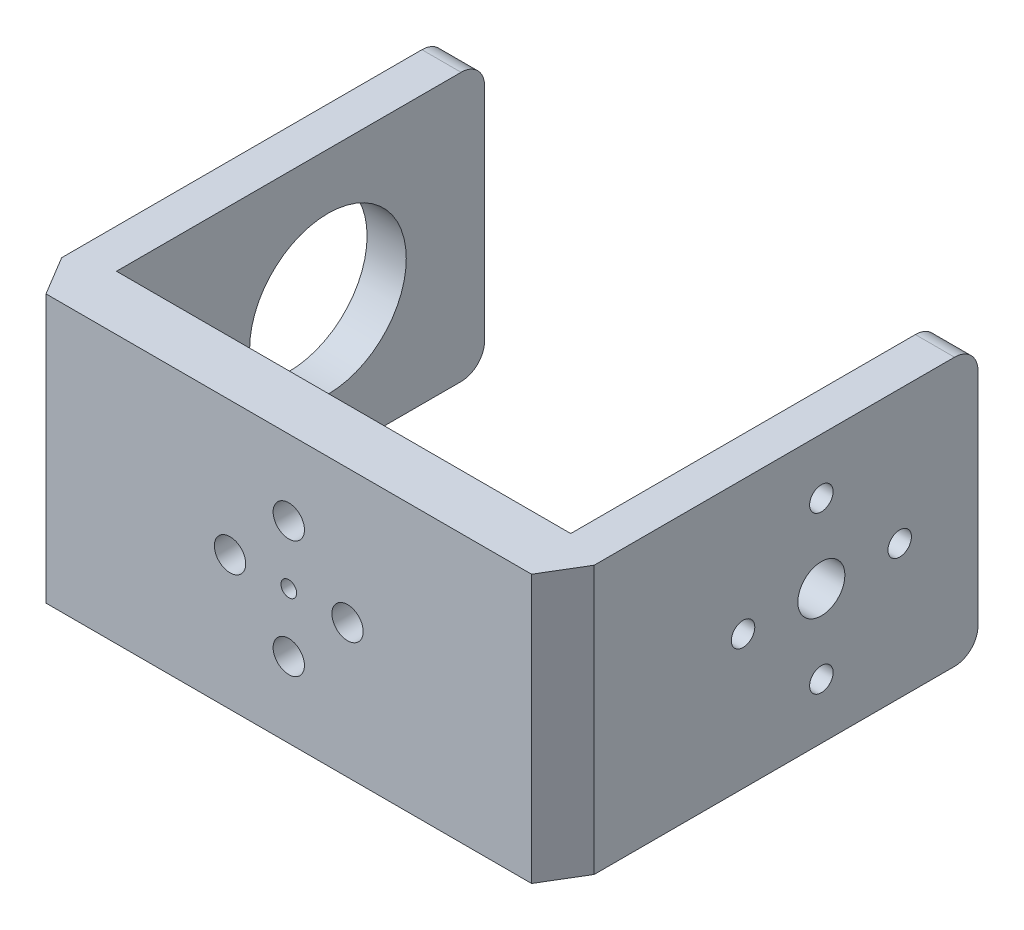
from build123d import *

# Parameters (mm, degrees)
BOSS_EXTRUDE1_DEPTH = 34.2
SKETCH4_R           = 2
SKETCH4_R_2         = 1
CUT_EXTRUDE3_DEPTH  = 7
FILLET1_R           = 3
SKETCH5_R           = 10
CUT_EXTRUDE4_DEPTH  = 5
SKETCH6_R           = 3
SKETCH6_R_2         = 1.5
CUT_EXTRUDE5_DEPTH  = 5


with BuildPart() as part:
    # Sketch1 → Boss-Extrude1 (new body)
    with BuildSketch(Plane(origin=(0, 0, 0), x_dir=(1, 0, 0), z_dir=(0, 1, 0))):
        Polygon((0, 0), (58, 0), (58, 47), (63, 47), (63, -2), (60, -7), (58, -7), (0, -7), (-2, -7), (-5, -2), (-5, 47), (0, 47), align=None)
    extrude(amount=BOSS_EXTRUDE1_DEPTH)

    # Sketch4 → Cut-Extrude3 (cut)
    with BuildSketch(Plane(origin=(0, 0, 0), x_dir=(-1, 0, 0), z_dir=(0, 0, -1))):
        with Locations((-29, 24.6)):
            Circle(SKETCH4_R)
        with Locations((-36.5, 17.1)):
            Circle(SKETCH4_R)
        with Locations((-21.5, 17.1)):
            Circle(SKETCH4_R)
        with Locations((-29, 9.6)):
            Circle(SKETCH4_R)
        with Locations((-29, 17.1)):
            Circle(SKETCH4_R_2)
    extrude(amount=-CUT_EXTRUDE3_DEPTH, mode=Mode.SUBTRACT)

    # Fillet1
    fillet1_edges = [part.edges().sort_by_distance(p)[0] for p in [
        (60.5, 0, -47),
        (-2.5, 0, -47),
        (60.5, 34.2, -47),
        (-2.5, 34.2, -47),
    ]]
    fillet(fillet1_edges, radius=FILLET1_R)

    # Sketch5 → Cut-Extrude4 (cut)
    with BuildSketch(Plane.ZY.offset(5)):
        with Locations((-27, 17.1)):
            Circle(SKETCH5_R)
    extrude(amount=-CUT_EXTRUDE4_DEPTH, mode=Mode.SUBTRACT)

    # Sketch6 → Cut-Extrude5 (cut)
    with BuildSketch(Plane(origin=(63, 0, 0), x_dir=(0, 0, -1), z_dir=(1, 0, 0))):
        with Locations((27, 17.1)):
            Circle(SKETCH6_R)
        with Locations((27, 27.1)):
            Circle(SKETCH6_R_2)
        with Locations((37, 17.1)):
            Circle(SKETCH6_R_2)
        with Locations((27, 7.1)):
            Circle(SKETCH6_R_2)
        with Locations((17, 17.1)):
            Circle(SKETCH6_R_2)
    extrude(amount=-CUT_EXTRUDE5_DEPTH, mode=Mode.SUBTRACT)


solid = part.part
